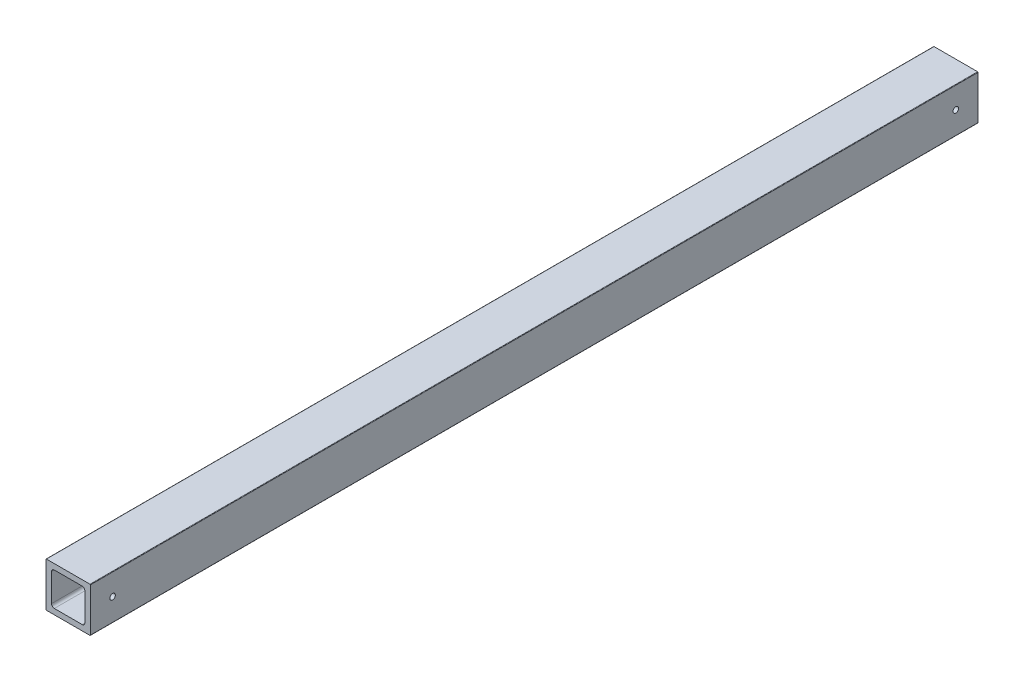
from build123d import *

# Parameters (mm, degrees)
BOSS_EXTRUDE1_DEPTH = 508
SKETCH2_R           = 1.5875
CUT_EXTRUDE1_DEPTH  = 26.4


with BuildPart() as part:
    # Sketch1 → Boss-Extrude1 (new body)
    with BuildSketch(Plane(origin=(0, 0, 0), x_dir=(-1, 0, 0), z_dir=(0, 0, -1))):
        with BuildLine():
            Line((0, 0.254), (0, 25.146))
            ThreePointArc((0, 25.146), (-0.074394878, 25.325605122), (-0.254, 25.4))
            Line((-0.254, 25.4), (-25.146, 25.4))
            ThreePointArc((-25.146, 25.4), (-25.325605122, 25.325605122), (-25.4, 25.146))
            Line((-25.4, 25.146), (-25.4, 0.254))
            ThreePointArc((-25.4, 0.254), (-25.325605122, 0.074394878), (-25.146, 0))
            Line((-25.146, 0), (-0.254, 0))
            ThreePointArc((-0.254, 0), (-0.074394878, 0.074394878), (0, 0.254))
        make_face()
        with BuildLine():
            Line((-3.175, 20.6375), (-3.175, 4.7625))
            ThreePointArc((-3.175, 4.7625), (-3.639967985, 3.639967985), (-4.7625, 3.175))
            Line((-4.7625, 3.175), (-20.6375, 3.175))
            ThreePointArc((-20.6375, 3.175), (-21.760032015, 3.639967985), (-22.225, 4.7625))
            Line((-22.225, 4.7625), (-22.225, 20.6375))
            ThreePointArc((-22.225, 20.6375), (-21.760032015, 21.760032015), (-20.6375, 22.225))
            Line((-20.6375, 22.225), (-4.7625, 22.225))
            ThreePointArc((-4.7625, 22.225), (-3.639967985, 21.760032015), (-3.175, 20.6375))
        make_face(mode=Mode.SUBTRACT)
    extrude(amount=-BOSS_EXTRUDE1_DEPTH)

    # Sketch2 → Cut-Extrude1 (cut, through all)
    with BuildSketch(Plane.ZY):
        with Locations((12.697459746, 12.954)):
            Circle(SKETCH2_R)
        with Locations((495.3, 12.954)):
            Circle(SKETCH2_R)
    extrude(amount=-CUT_EXTRUDE1_DEPTH, mode=Mode.SUBTRACT)


solid = part.part
